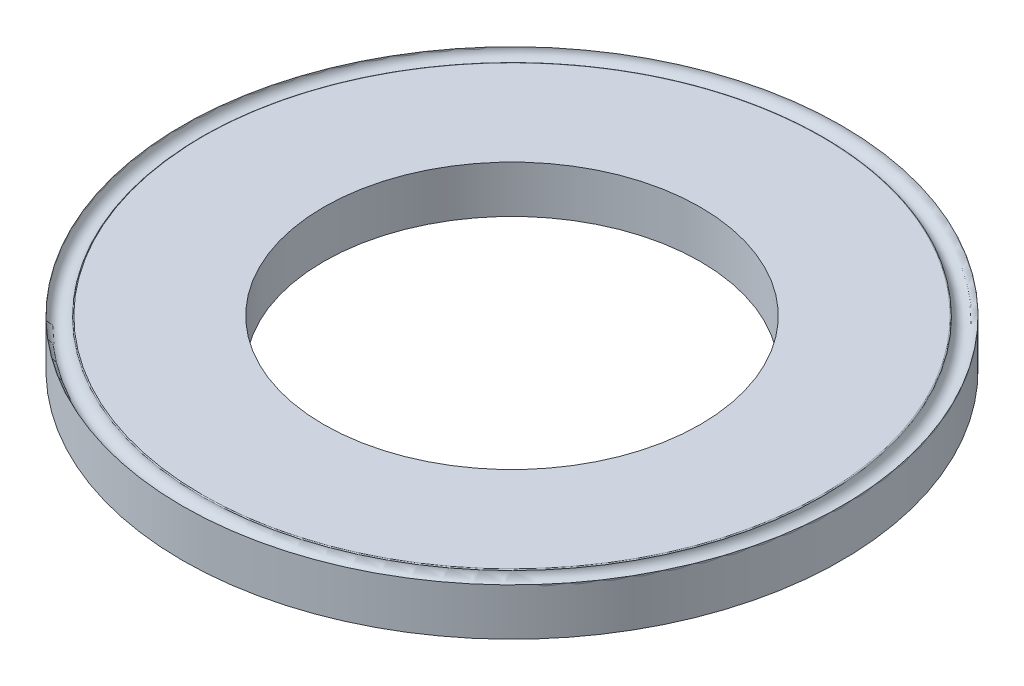
from build123d import *

# Parameters (mm, degrees)
DIAPROFILES_R    = 3.5
DIAPROFILES_R_2  = 2
DIAPROFILE_DEPTH = 0.25


with BuildPart() as part:
    # DiaProfileS → DiaProfile (new body, symmetric)
    with BuildSketch(Plane(origin=(0, 0, 0), x_dir=(1, 0, 0), z_dir=(0, 1, 0))):
        Circle(DIAPROFILES_R)
        Circle(DIAPROFILES_R_2, mode=Mode.SUBTRACT)
    extrude(amount=DIAPROFILE_DEPTH, both=True)

    # CrimpS → Crimp (revolve, cut)
    with BuildSketch(Plane.XY):
        with BuildLine():
            Line((-3.5, 0.25), (-3.290455488, 0.25))
            ThreePointArc((-3.290455488, 0.25), (-3.297197487, 0.247385489), (-3.30041408, 0.240909091))
            ThreePointArc((-3.30041408, 0.240909091), (-3.404550167, 0.150103574), (-3.5, 0.25))
        make_face()
    revolve(axis=Axis((0, 0.25, 0), (0, -1, 0)), mode=Mode.SUBTRACT)


solid = part.part
